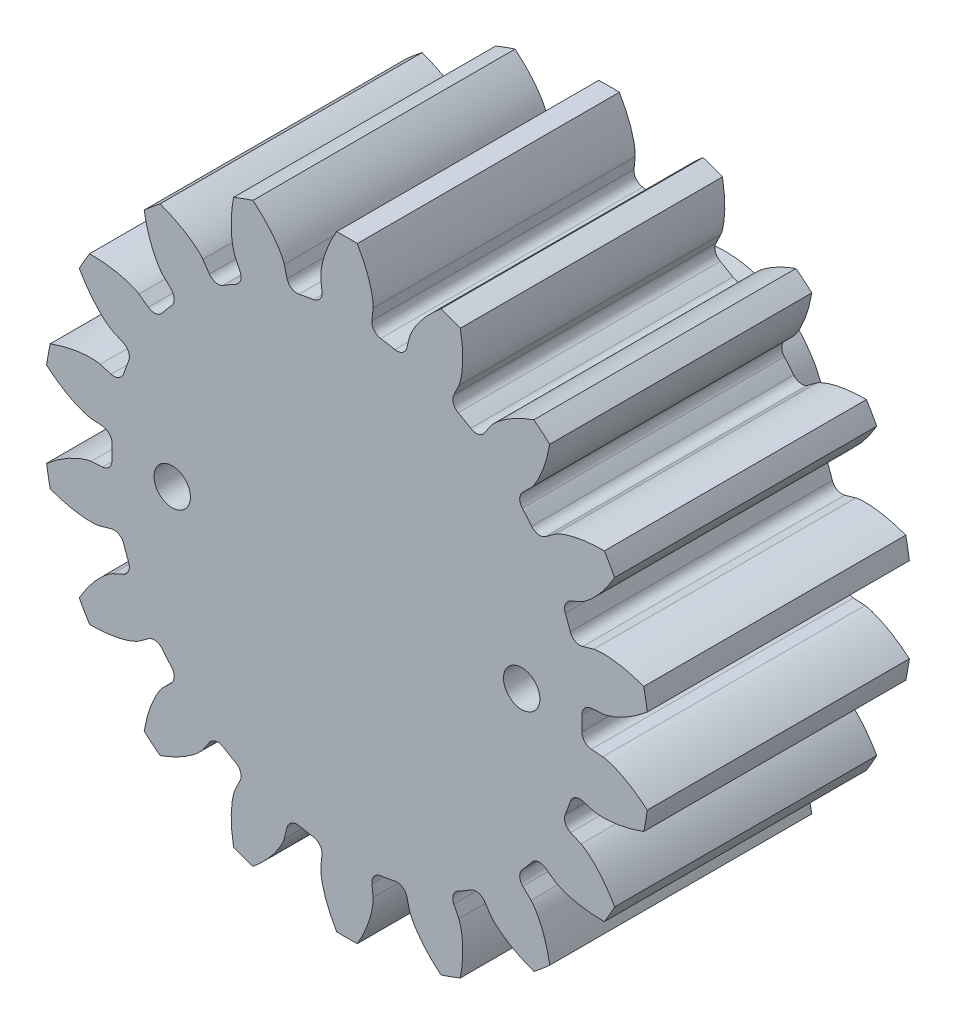
from build123d import *

# Parameters (mm, degrees)
SKETCH3_R                = 10.583333333
BOSS_EXTRUDE1_DEPTH      = 15.24
CUT_EXTRUDE1_START       = -16.24
CUT_EXTRUDE1_DEPTH       = 17.24
FILLET1_R                = 0.355076163
CIRPATTERN1_COUNT        = 18
FILLET1_OF_CIRPATTERN1_R = 0.355076163
SCALE3_SCALE             = 2.5
SKETCH10_R               = 3.175
CUT_EXTRUDE4_DEPTH       = 0.0254
SKETCH11_R               = 3.048
CUT_EXTRUDE5_DEPTH       = 8.636
SKETCH15_R               = 29.344199696
SKETCH15_R_2             = 8.89
CUT_EXTRUDE8_DEPTH       = 10.16
SKETCH16_R               = 27.94
CUT_EXTRUDE9_DEPTH       = 5.08
CUT_EXTRUDE10_DEPTH      = 12.7
CUT_EXTRUDE11_REACH      = 12.16
SKETCH18_R               = 1.5875


with BuildPart() as part:
    # Sketch3 → Boss-Extrude1 (new body)
    with BuildSketch(Plane.XY):
        Circle(SKETCH3_R)
    extrude(amount=-BOSS_EXTRUDE1_DEPTH)

    # Sketch4 → Cut-Extrude1 (cut)
    with BuildSketch(Plane.XY.offset(CUT_EXTRUDE1_START)):
        with BuildLine():
            Line((8.180618539, 0.593001964), (8.927148628, 0.647116919))
            add(Edge.make_bspline(
                [(8.927148628, 0.647116919), (8.929773603, 0.64734246), (8.937126743, 0.648083571), (8.950989701, 0.649913095), (8.97354406, 0.653505718), (9.002174883, 0.658974713), (9.039040294, 0.667064652), (9.08227108, 0.677905244), (9.129552823, 0.691187893), (9.180725702, 0.707111733), (9.231524372, 0.724296782), (9.281946361, 0.742644429), (9.331936661, 0.762005639), (9.392192531, 0.786734306), (9.464019144, 0.81815733), (9.547307729, 0.857451379), (9.640949476, 0.905033405), (9.735448155, 0.956729189), (9.827643658, 1.01022152), (9.919826595, 1.067258688), (10.008328253, 1.124562674), (10.099192996, 1.187113225), (10.182530598, 1.246394384), (10.274659666, 1.316128649), (10.348652098, 1.373376845), (10.424010343, 1.435256389), (10.460526963, 1.465776942), (10.479120716, 1.481544284)],
                knots=[0, 0, 0, 0, 0, 0.005376749, 0.015083688, 0.02853182, 0.04661014, 0.064854849, 0.092110526, 0.119476176, 0.146842496, 0.174208854, 0.201574956, 0.228941013, 0.256307345, 0.307035032, 0.361767352, 0.416499661, 0.471231937, 0.525964282, 0.580696616, 0.635428982, 0.690161387, 0.744893688, 0.799626082, 0.854358407, 0.909090915, 0.909090915, 0.909090915, 0.909090915, 0.909090915], degree=4))
            ThreePointArc((10.479120716, 1.481544284), (10.583333333, 0), (10.479120716, -1.481544284))
            add(Edge.make_bspline(
                [(8.927148628, -0.647116919), (8.929773603, -0.64734246), (8.937126743, -0.648083571), (8.950989701, -0.649913095), (8.97354406, -0.653505718), (9.002174883, -0.658974713), (9.039040294, -0.667064652), (9.08227108, -0.677905244), (9.129552823, -0.691187893), (9.180725702, -0.707111733), (9.231524372, -0.724296782), (9.281946361, -0.742644429), (9.331936661, -0.762005639), (9.392192531, -0.786734306), (9.464019144, -0.81815733), (9.547307729, -0.857451379), (9.640949476, -0.905033405), (9.735448155, -0.956729189), (9.827643658, -1.01022152), (9.919826595, -1.067258688), (10.008328253, -1.124562674), (10.099192996, -1.187113225), (10.182530598, -1.246394384), (10.274659666, -1.316128649), (10.348652098, -1.373376845), (10.424010343, -1.435256389), (10.460526963, -1.465776942), (10.479120716, -1.481544284)],
                knots=[0, 0, 0, 0, 0, 0.005376749, 0.015083688, 0.02853182, 0.04661014, 0.064854849, 0.092110526, 0.119476176, 0.146842496, 0.174208854, 0.201574956, 0.228941013, 0.256307345, 0.307035032, 0.361767352, 0.416499661, 0.471231937, 0.525964282, 0.580696616, 0.635428982, 0.690161387, 0.744893688, 0.799626082, 0.854358407, 0.909090915, 0.909090915, 0.909090915, 0.909090915, 0.909090915], degree=4))
            Line((8.927148628, -0.647116919), (8.180618539, -0.593001964))
            ThreePointArc((8.180618539, -0.593001964), (8.202083333, 0), (8.180618539, 0.593001964))
        make_face()
    cut_extrude1 = extrude(amount=CUT_EXTRUDE1_DEPTH, mode=Mode.SUBTRACT)

    # Fillet1
    fillet1_edges = [part.edges().sort_by_distance(p)[0] for p in [
        (8.180618539, -0.593001964, -7.62),
        (8.180618539, 0.593001964, -7.62),
    ]]
    fillet(fillet1_edges, radius=FILLET1_R)

    # CirPattern1: Cut-Extrude1 ×18 about axis
    cirpattern1_axis = Axis((0, 0, 6.35), (0, 0, -1))
    for i in range(1, CIRPATTERN1_COUNT):
        add(cut_extrude1.rotate(cirpattern1_axis, i * 360 / CIRPATTERN1_COUNT), mode=Mode.SUBTRACT)

    # Fillet1 of CirPattern1
    fillet1_of_cirpattern1_edges = [part.edges().sort_by_distance(p)[0] for p in [
        (7.484448258, -3.355175895, -7.62),
        (7.890085491, -2.240696756, -7.62),
        (5.885543058, -5.712666095, -7.62),
        (6.647891688, -4.804134377, -7.62),
        (3.576754504, -7.381124455, -7.62),
        (4.603864035, -6.788122491, -7.62),
        (0.83655657, -8.159310272, -7.62),
        (2.004542433, -7.953362851, -7.62),
        (-2.004542433, -7.953362851, -7.62),
        (-0.83655657, -8.159310272, -7.62),
        (-4.603864035, -6.788122491, -7.62),
        (-3.576754504, -7.381124455, -7.62),
        (-6.647891688, -4.804134377, -7.62),
        (-5.885543058, -5.712666095, -7.62),
        (-7.890085491, -2.240696756, -7.62),
        (-7.484448258, -3.355175895, -7.62),
        (-8.180618539, 0.593001964, -7.62),
        (-8.180618539, -0.593001964, -7.62),
        (-7.484448258, 3.355175895, -7.62),
        (-7.890085491, 2.240696756, -7.62),
        (-5.885543058, 5.712666095, -7.62),
        (-6.647891688, 4.804134377, -7.62),
        (-3.576754504, 7.381124455, -7.62),
        (-4.603864035, 6.788122491, -7.62),
        (-0.83655657, 8.159310272, -7.62),
        (-2.004542433, 7.953362851, -7.62),
        (2.004542433, 7.953362851, -7.62),
        (0.83655657, 8.159310272, -7.62),
        (4.603864035, 6.788122491, -7.62),
        (3.576754504, 7.381124455, -7.62),
        (6.647891688, 4.804134377, -7.62),
        (5.885543058, 5.712666095, -7.62),
        (7.890085491, 2.240696756, -7.62),
        (7.484448258, 3.355175895, -7.62),
    ]]
    fillet(fillet1_of_cirpattern1_edges, radius=FILLET1_OF_CIRPATTERN1_R)


with BuildPart() as part_1:
    # Scale3: scaled about (0, 0, 0)
    add(part.part.scale(SCALE3_SCALE))

    # Sketch10 → Cut-Extrude4 (cut)
    with BuildSketch(Plane.XY):
        Circle(SKETCH10_R)
    extrude(amount=-CUT_EXTRUDE4_DEPTH, mode=Mode.SUBTRACT)

    # Sketch11 → Cut-Extrude5 (cut)
    with BuildSketch(Plane(origin=(0, 0, -38.1), x_dir=(-1, 0, 0), z_dir=(0, 0, -1))):
        Circle(SKETCH11_R)
    extrude(amount=-CUT_EXTRUDE5_DEPTH, mode=Mode.SUBTRACT)

    # Sketch15 → Cut-Extrude8 (cut)
    with BuildSketch(Plane(origin=(0, 0, -38.1), x_dir=(-1, 0, 0), z_dir=(0, 0, -1))):
        Circle(SKETCH15_R)
        Circle(SKETCH15_R_2, mode=Mode.SUBTRACT)
    extrude(amount=-CUT_EXTRUDE8_DEPTH, mode=Mode.SUBTRACT)

    # Sketch16 → Cut-Extrude9 (cut)
    with BuildSketch(Plane.XY):
        Circle(SKETCH16_R)
    extrude(amount=-CUT_EXTRUDE9_DEPTH, mode=Mode.SUBTRACT)

    # Sketch17 → Cut-Extrude10 (cut)
    with BuildSketch(Plane(origin=(0, 0, -27.94), x_dir=(-1, 0, 0), z_dir=(0, 0, -1))):
        Polygon((-11.940443212, 0), (-13.590221606, 2.8575), (-16.889778394, 2.8575), (-18.539556788, 0), (-16.889778394, -2.8575), (-13.590221606, -2.8575), align=None)
        Polygon((18.539556788, 0), (16.889778394, 2.8575), (13.590221606, 2.8575), (11.940443212, 0), (13.590221606, -2.8575), (16.889778394, -2.8575), align=None)
    extrude(amount=-CUT_EXTRUDE10_DEPTH, mode=Mode.SUBTRACT)

    # Sketch18 → Cut-Extrude11 (cut, up to next)
    with BuildSketch(Plane(origin=(0, 0, -15.24), x_dir=(-1, 0, 0), z_dir=(0, 0, -1)), mode=Mode.PRIVATE) as cut_extrude11_sk1:
        with Locations((15.24, 0)):
            Circle(SKETCH18_R)
    cut_extrude11_tool1 = extrude(cut_extrude11_sk1.sketch, amount=-CUT_EXTRUDE11_REACH, mode=Mode.PRIVATE) & part_1.part
    add(cut_extrude11_tool1.solids().sort_by_distance((-15.24, 0, -15.24))[0], mode=Mode.SUBTRACT)
    # Sketch18 → Cut-Extrude11 (cut, up to next)
    with BuildSketch(Plane(origin=(0, 0, -15.24), x_dir=(-1, 0, 0), z_dir=(0, 0, -1)), mode=Mode.PRIVATE) as cut_extrude11_sk2:
        with Locations((-15.24, 0)):
            Circle(SKETCH18_R)
    cut_extrude11_tool2 = extrude(cut_extrude11_sk2.sketch, amount=-CUT_EXTRUDE11_REACH, mode=Mode.PRIVATE) & part_1.part
    add(cut_extrude11_tool2.solids().sort_by_distance((15.24, 0, -15.24))[0], mode=Mode.SUBTRACT)


solid = part_1.part
